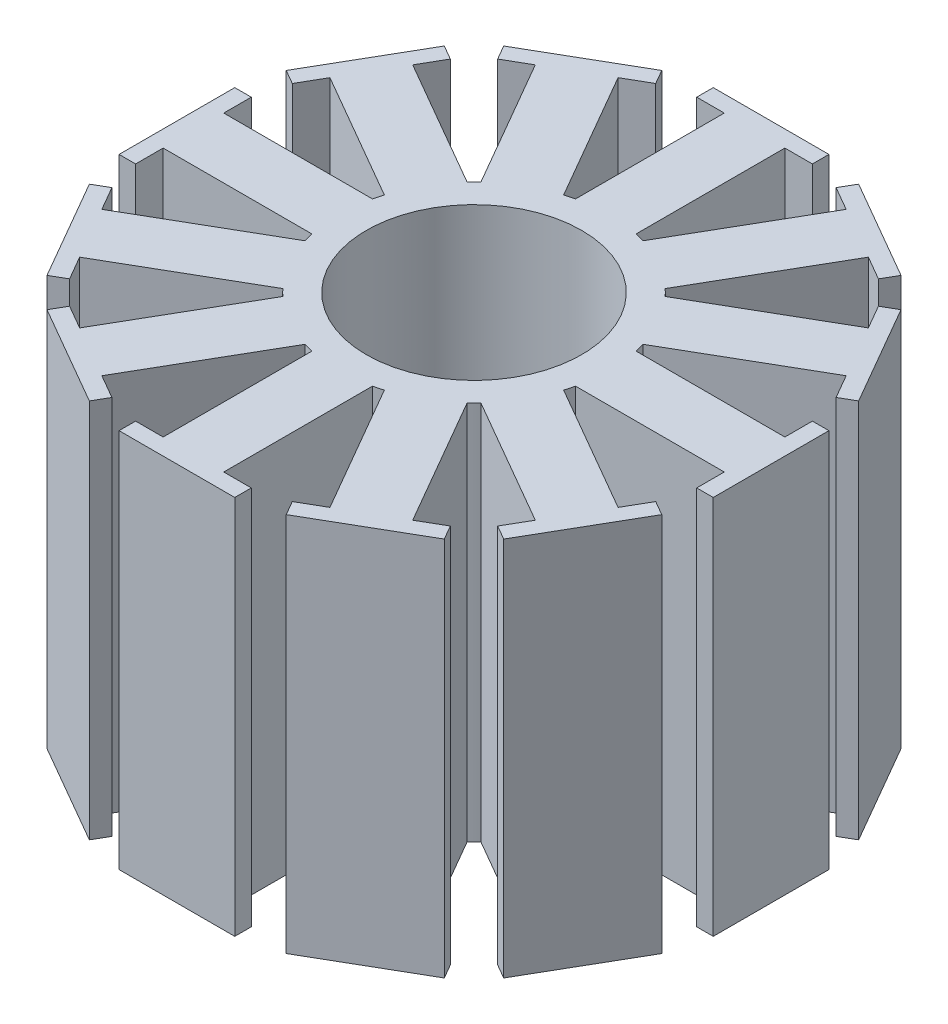
from build123d import *

# Parameters (mm, degrees)
SKETCH2_R           = 4.91
SKETCH2_R_2         = 3.91
BOSS_EXTRUDE1_DEPTH = 13.8
BOSS_EXTRUDE2_DEPTH = 13.8


with BuildPart() as part:
    # Sketch2 → Boss-Extrude1 (new body)
    with BuildSketch(Plane(origin=(0, 0, 0), x_dir=(1, 0, 0), z_dir=(0, 1, 0))):
        Circle(SKETCH2_R)
        Circle(SKETCH2_R_2, mode=Mode.SUBTRACT)
    extrude(amount=BOSS_EXTRUDE1_DEPTH)

    # Sketch3 → Boss-Extrude2 (add)
    with BuildSketch(Plane(origin=(0, 13.8, 0), x_dir=(1, 0, 0), z_dir=(0, 1, 0))):
        with BuildLine():
            Line((4.785195921, 1.1), (10.185195921, 1.1))
            Line((10.185195921, 1.1), (10.185195921, 2.1))
            Line((10.185195921, 2.1), (10.785195921, 2.1))
            Line((10.785195921, 2.1), (10.785195921, -2.1))
            Line((10.785195921, -2.1), (10.185195921, -2.1))
            Line((10.185195921, -2.1), (10.185195921, -1.1))
            Line((10.185195921, -1.1), (4.785195921, -1.1))
            ThreePointArc((4.785195921, -1.1), (4.91, 0), (4.785195921, 1.1))
        make_face()
        with BuildLine():
            Line((4.694101229, -1.439970016), (9.37063841, -4.139970016))
            Line((9.37063841, -4.139970016), (9.87063841, -3.273944612))
            Line((9.87063841, -3.273944612), (10.390253652, -3.573944612))
            Line((10.390253652, -3.573944612), (8.290253652, -7.211251308))
            Line((8.290253652, -7.211251308), (7.77063841, -6.911251308))
            Line((7.77063841, -6.911251308), (8.27063841, -6.045225905))
            Line((8.27063841, -6.045225905), (3.594101229, -3.345225905))
            ThreePointArc((3.594101229, -3.345225905), (4.252184733, -2.455), (4.694101229, -1.439970016))
        make_face()
        with BuildLine():
            Line((3.345225905, -3.594101229), (6.045225905, -8.27063841))
            Line((6.045225905, -8.27063841), (6.911251308, -7.77063841))
            Line((6.911251308, -7.77063841), (7.211251308, -8.290253652))
            Line((7.211251308, -8.290253652), (3.573944612, -10.390253652))
            Line((3.573944612, -10.390253652), (3.273944612, -9.87063841))
            Line((3.273944612, -9.87063841), (4.139970016, -9.37063841))
            Line((4.139970016, -9.37063841), (1.439970016, -4.694101229))
            ThreePointArc((1.439970016, -4.694101229), (2.455, -4.252184733), (3.345225905, -3.594101229))
        make_face()
        with BuildLine():
            Line((1.1, -4.785195921), (1.1, -10.185195921))
            Line((1.1, -10.185195921), (2.1, -10.185195921))
            Line((2.1, -10.185195921), (2.1, -10.785195921))
            Line((2.1, -10.785195921), (-2.1, -10.785195921))
            Line((-2.1, -10.785195921), (-2.1, -10.185195921))
            Line((-2.1, -10.185195921), (-1.1, -10.185195921))
            Line((-1.1, -10.185195921), (-1.1, -4.785195921))
            ThreePointArc((-1.1, -4.785195921), (0, -4.91), (1.1, -4.785195921))
        make_face()
        with BuildLine():
            Line((-1.439970016, -4.694101229), (-4.139970016, -9.37063841))
            Line((-4.139970016, -9.37063841), (-3.273944612, -9.87063841))
            Line((-3.273944612, -9.87063841), (-3.573944612, -10.390253652))
            Line((-3.573944612, -10.390253652), (-7.211251308, -8.290253652))
            Line((-7.211251308, -8.290253652), (-6.911251308, -7.77063841))
            Line((-6.911251308, -7.77063841), (-6.045225905, -8.27063841))
            Line((-6.045225905, -8.27063841), (-3.345225905, -3.594101229))
            ThreePointArc((-3.345225905, -3.594101229), (-2.455, -4.252184733), (-1.439970016, -4.694101229))
        make_face()
        with BuildLine():
            Line((-3.594101229, -3.345225905), (-8.27063841, -6.045225905))
            Line((-8.27063841, -6.045225905), (-7.77063841, -6.911251308))
            Line((-7.77063841, -6.911251308), (-8.290253652, -7.211251308))
            Line((-8.290253652, -7.211251308), (-10.390253652, -3.573944612))
            Line((-10.390253652, -3.573944612), (-9.87063841, -3.273944612))
            Line((-9.87063841, -3.273944612), (-9.37063841, -4.139970016))
            Line((-9.37063841, -4.139970016), (-4.694101229, -1.439970016))
            ThreePointArc((-4.694101229, -1.439970016), (-4.252184733, -2.455), (-3.594101229, -3.345225905))
        make_face()
        with BuildLine():
            Line((-4.785195921, -1.1), (-10.185195921, -1.1))
            Line((-10.185195921, -1.1), (-10.185195921, -2.1))
            Line((-10.185195921, -2.1), (-10.785195921, -2.1))
            Line((-10.785195921, -2.1), (-10.785195921, 2.1))
            Line((-10.785195921, 2.1), (-10.185195921, 2.1))
            Line((-10.185195921, 2.1), (-10.185195921, 1.1))
            Line((-10.185195921, 1.1), (-4.785195921, 1.1))
            ThreePointArc((-4.785195921, 1.1), (-4.91, 0), (-4.785195921, -1.1))
        make_face()
        with BuildLine():
            Line((-4.694101229, 1.439970016), (-9.37063841, 4.139970016))
            Line((-9.37063841, 4.139970016), (-9.87063841, 3.273944612))
            Line((-9.87063841, 3.273944612), (-10.390253652, 3.573944612))
            Line((-10.390253652, 3.573944612), (-8.290253652, 7.211251308))
            Line((-8.290253652, 7.211251308), (-7.77063841, 6.911251308))
            Line((-7.77063841, 6.911251308), (-8.27063841, 6.045225905))
            Line((-8.27063841, 6.045225905), (-3.594101229, 3.345225905))
            ThreePointArc((-3.594101229, 3.345225905), (-4.252184733, 2.455), (-4.694101229, 1.439970016))
        make_face()
        with BuildLine():
            Line((-3.345225905, 3.594101229), (-6.045225905, 8.27063841))
            Line((-6.045225905, 8.27063841), (-6.911251308, 7.77063841))
            Line((-6.911251308, 7.77063841), (-7.211251308, 8.290253652))
            Line((-7.211251308, 8.290253652), (-3.573944612, 10.390253652))
            Line((-3.573944612, 10.390253652), (-3.273944612, 9.87063841))
            Line((-3.273944612, 9.87063841), (-4.139970016, 9.37063841))
            Line((-4.139970016, 9.37063841), (-1.439970016, 4.694101229))
            ThreePointArc((-1.439970016, 4.694101229), (-2.455, 4.252184733), (-3.345225905, 3.594101229))
        make_face()
        with BuildLine():
            Line((-1.1, 4.785195921), (-1.1, 10.185195921))
            Line((-1.1, 10.185195921), (-2.1, 10.185195921))
            Line((-2.1, 10.185195921), (-2.1, 10.785195921))
            Line((-2.1, 10.785195921), (2.1, 10.785195921))
            Line((2.1, 10.785195921), (2.1, 10.185195921))
            Line((2.1, 10.185195921), (1.1, 10.185195921))
            Line((1.1, 10.185195921), (1.1, 4.785195921))
            ThreePointArc((1.1, 4.785195921), (0, 4.91), (-1.1, 4.785195921))
        make_face()
        with BuildLine():
            Line((1.439970016, 4.694101229), (4.139970016, 9.37063841))
            Line((4.139970016, 9.37063841), (3.273944612, 9.87063841))
            Line((3.273944612, 9.87063841), (3.573944612, 10.390253652))
            Line((3.573944612, 10.390253652), (7.211251308, 8.290253652))
            Line((7.211251308, 8.290253652), (6.911251308, 7.77063841))
            Line((6.911251308, 7.77063841), (6.045225905, 8.27063841))
            Line((6.045225905, 8.27063841), (3.345225905, 3.594101229))
            ThreePointArc((3.345225905, 3.594101229), (2.455, 4.252184733), (1.439970016, 4.694101229))
        make_face()
        with BuildLine():
            Line((3.594101229, 3.345225905), (8.27063841, 6.045225905))
            Line((8.27063841, 6.045225905), (7.77063841, 6.911251308))
            Line((7.77063841, 6.911251308), (8.290253652, 7.211251308))
            Line((8.290253652, 7.211251308), (10.390253652, 3.573944612))
            Line((10.390253652, 3.573944612), (9.87063841, 3.273944612))
            Line((9.87063841, 3.273944612), (9.37063841, 4.139970016))
            Line((9.37063841, 4.139970016), (4.694101229, 1.439970016))
            ThreePointArc((4.694101229, 1.439970016), (4.252184733, 2.455), (3.594101229, 3.345225905))
        make_face()
    extrude(amount=-BOSS_EXTRUDE2_DEPTH)


solid = part.part
